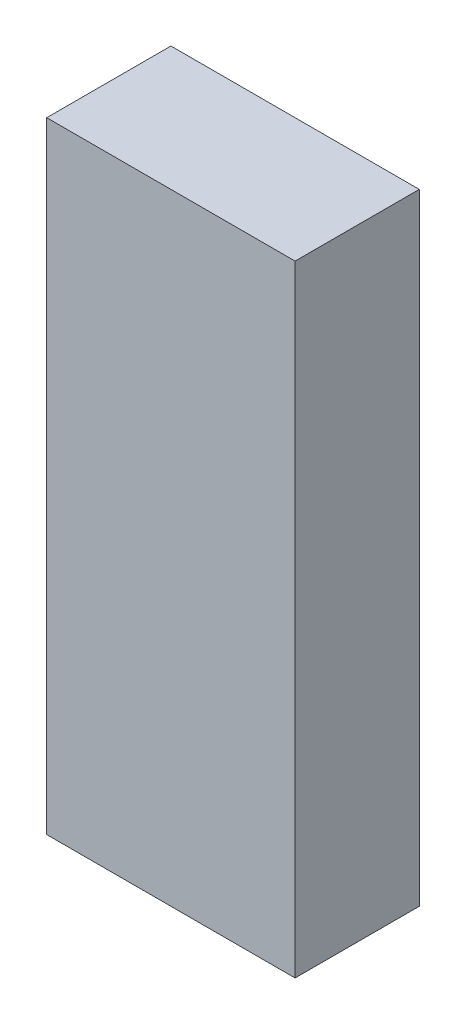
from build123d import *

# Parameters (mm, degrees)
SKETCH1_W           = 200
SKETCH1_H           = 100
BOSS_EXTRUDE1_DEPTH = 500


with BuildPart() as part:
    # Sketch1 → Boss-Extrude1 (new body)
    with BuildSketch(Plane(origin=(0, 0, 0), x_dir=(1, 0, 0), z_dir=(0, 1, 0))):
        with Locations((100, 50)):
            Rectangle(SKETCH1_W, SKETCH1_H)
    extrude(amount=BOSS_EXTRUDE1_DEPTH)


solid = part.part
